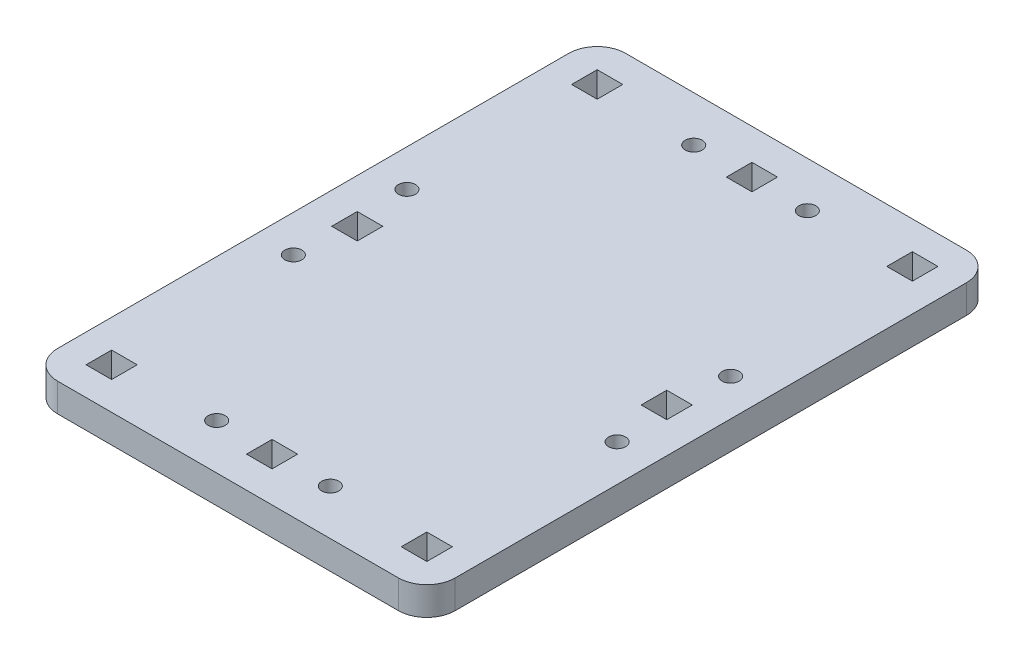
from build123d import *

# Parameters (mm, degrees)
SKETCH1_R           = 1.5
SKETCH1_W           = 4.5
SKETCH1_H           = 4.5
BOSS_EXTRUDE1_DEPTH = 2.5


with BuildPart() as part:
    # Sketch1 → Boss-Extrude1 (new body, symmetric)
    with BuildSketch(Plane(origin=(0, 0, 0), x_dir=(1, 0, 0), z_dir=(0, 1, 0))):
        with BuildLine():
            Line((-30, 50), (30, 50))
            ThreePointArc((30, 50), (33.535533906, 48.535533906), (35, 45))
            Line((35, 45), (35, -45))
            ThreePointArc((35, -45), (33.535533906, -48.535533906), (30, -50))
            Line((30, -50), (-30, -50))
            ThreePointArc((-30, -50), (-33.535533906, -48.535533906), (-35, -45))
            Line((-35, -45), (-35, 45))
            ThreePointArc((-35, 45), (-33.535533906, 48.535533906), (-30, 50))
        make_face()
        with Locations((10, 42)):
            Circle(SKETCH1_R, mode=Mode.SUBTRACT)
        with Locations((10, -42)):
            Circle(SKETCH1_R, mode=Mode.SUBTRACT)
        with Locations((-10, -42)):
            Circle(SKETCH1_R, mode=Mode.SUBTRACT)
        with Locations((-10, 42)):
            Circle(SKETCH1_R, mode=Mode.SUBTRACT)
        with Locations((28.5, 10)):
            Circle(SKETCH1_R, mode=Mode.SUBTRACT)
        with Locations((28.5, -10)):
            Circle(SKETCH1_R, mode=Mode.SUBTRACT)
        with Locations((-28.5, -10)):
            Circle(SKETCH1_R, mode=Mode.SUBTRACT)
        with Locations((-28.5, 10)):
            Circle(SKETCH1_R, mode=Mode.SUBTRACT)
        with Locations((27.25, 0)):
            Rectangle(SKETCH1_W, SKETCH1_H, mode=Mode.SUBTRACT)
        with Locations((0, -42.25)):
            Rectangle(SKETCH1_W, SKETCH1_H, mode=Mode.SUBTRACT)
        with Locations((0, 42.25)):
            Rectangle(SKETCH1_W, SKETCH1_H, mode=Mode.SUBTRACT)
        with Locations((-27.25, 0)):
            Rectangle(SKETCH1_W, SKETCH1_H, mode=Mode.SUBTRACT)
        with Locations((27.75, -42.75)):
            Rectangle(SKETCH1_W, SKETCH1_H, mode=Mode.SUBTRACT)
        with Locations((27.75, 42.75)):
            Rectangle(SKETCH1_W, SKETCH1_H, mode=Mode.SUBTRACT)
        with Locations((-27.75, 42.75)):
            Rectangle(SKETCH1_W, SKETCH1_H, mode=Mode.SUBTRACT)
        with Locations((-27.75, -42.75)):
            Rectangle(SKETCH1_W, SKETCH1_H, mode=Mode.SUBTRACT)
    extrude(amount=BOSS_EXTRUDE1_DEPTH, both=True)


solid = part.part
